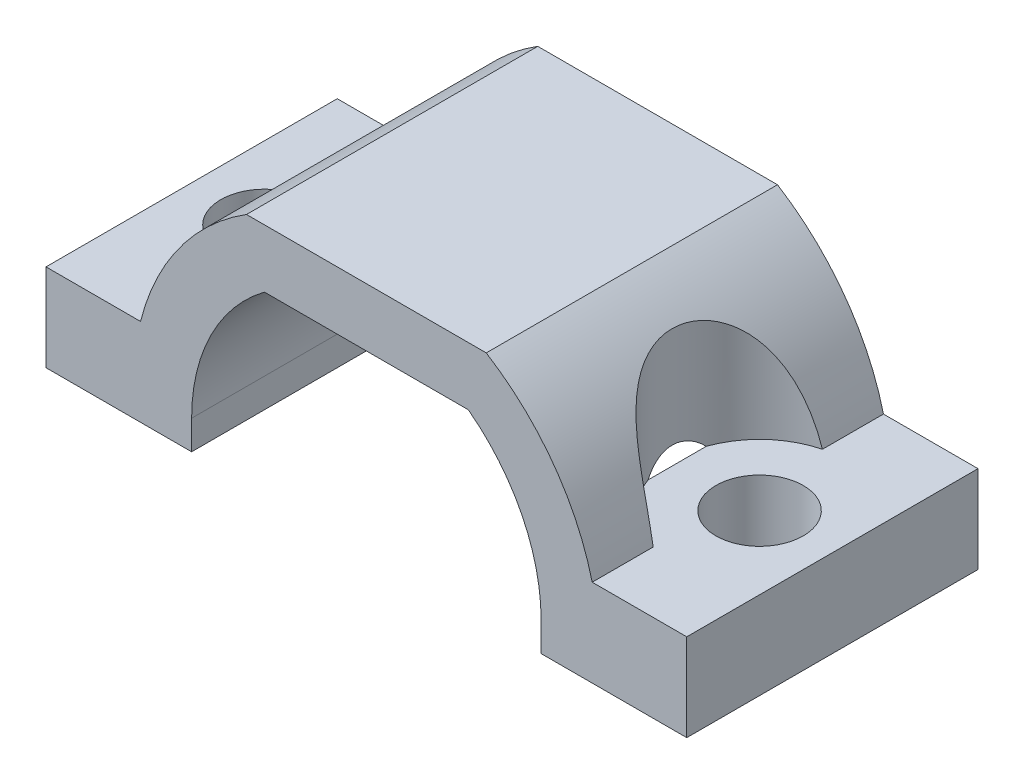
from build123d import *

# Parameters (mm, degrees)
EXTRUDE_1_DEPTH     = 5
SKETCH_3_R          = 1.5
CUT_EXTRUDE_1_DEPTH = 9
SKETCH_4_R          = 3
CUT_EXTRUDE_2_DEPTH = 5


with BuildPart() as part:
    # 草圖1 → 填料-伸長1 (new body, symmetric)
    with BuildSketch(Plane.XY):
        with BuildLine():
            Line((-4.116062299, 0), (4.116062299, 0))
            ThreePointArc((4.116062299, 0), (6.42113368, -2.146292611), (7.753905297, -5))
            Line((7.753905297, -5), (11, -5))
            Line((11, -5), (11, -8))
            Line((11, -8), (6, -8))
            Line((6, -8), (6, -7))
            ThreePointArc((6, -7), (5.340169944, -4.204915028), (3.5, -2))
            Line((3.5, -2), (-3.5, -2))
            ThreePointArc((-3.5, -2), (-5.340169944, -4.204915028), (-6, -7))
            Line((-6, -7), (-6, -8))
            Line((-6, -8), (-11, -8))
            Line((-11, -8), (-11, -5))
            Line((-11, -5), (-7.753905297, -5))
            ThreePointArc((-7.753905297, -5), (-6.42113368, -2.146292611), (-4.116062299, 0))
        make_face()
    extrude(amount=EXTRUDE_1_DEPTH, both=True)

    # 草圖3 → 除料-伸長1 (cut, through all)
    with BuildSketch(Plane.XZ.offset(8)):
        with Locations((-8.5, 0)):
            Circle(SKETCH_3_R)
        with Locations((8.5, 0)):
            Circle(SKETCH_3_R)
    extrude(amount=-CUT_EXTRUDE_1_DEPTH, mode=Mode.SUBTRACT)

    # 草圖4 → 除料-伸長2 (cut)
    with BuildSketch(Plane(origin=(0, 0, 0), x_dir=(1, 0, 0), z_dir=(0, 1, 0))):
        with Locations((8.5, 0)):
            Circle(SKETCH_4_R)
        with Locations((-8.5, 0)):
            Circle(SKETCH_4_R)
    extrude(amount=-CUT_EXTRUDE_2_DEPTH, mode=Mode.SUBTRACT)


solid = part.part
